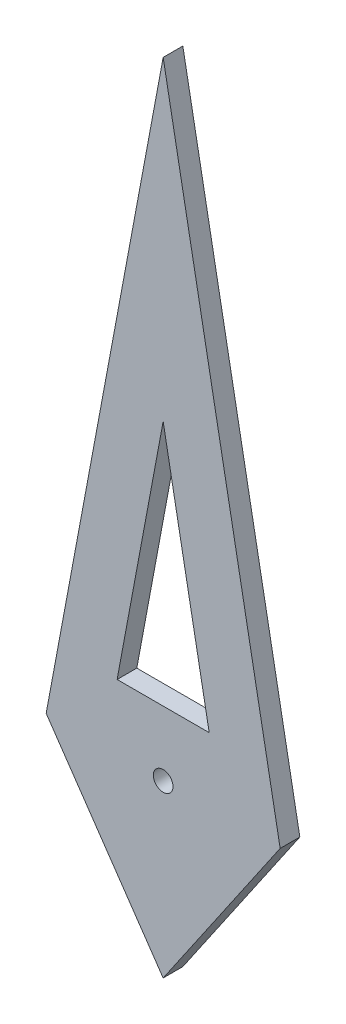
from build123d import *

# Parameters (mm, degrees)
SKETCH1_R           = 0.05
BOSS_EXTRUDE1_DEPTH = 0.1


with BuildPart() as part:
    # Sketch1 → Boss-Extrude1 (new body)
    with BuildSketch(Plane.XY):
        Polygon((0, 3.1840221), (0.594549459, 0), (0, -0.867569573), (-0.594549459, 0), align=None)
        Circle(SKETCH1_R, mode=Mode.SUBTRACT)
        Polygon((-0.233954096, 0.329177116), (0.233954096, 0.329177116), (0, 1.582083838), align=None, mode=Mode.SUBTRACT)
    extrude(amount=BOSS_EXTRUDE1_DEPTH)


solid = part.part
